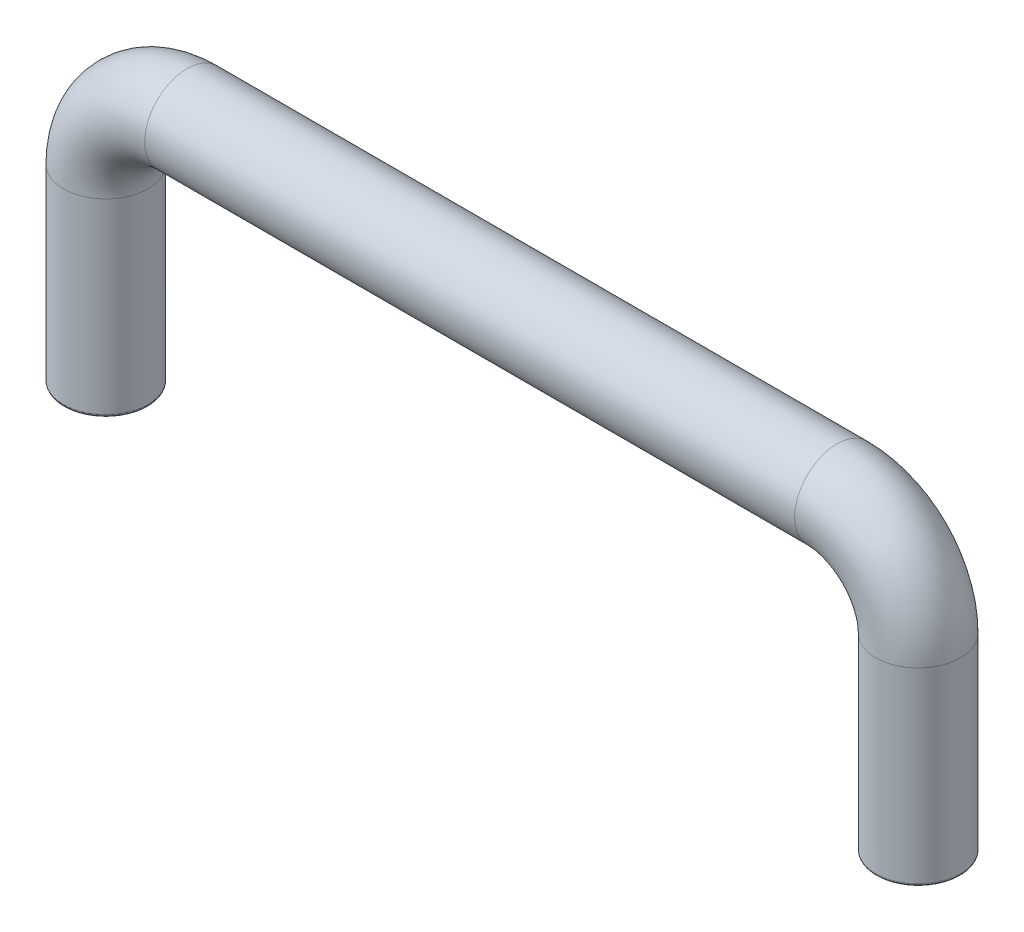
from build123d import *

# Parameters (mm, degrees)
SKETCH2_R                     = 3.96875
TAP_DRILL_FOR_8_32_TAP1_D     = 3.4544
TAP_DRILL_FOR_8_32_TAP1_DEPTH = 7.96925
TAP_DRILL_FOR_8_32_TAP1_TIP   = 1.037806461
FILLET1_R                     = 0.254


with BuildPart() as part:
    # Sweep5: sweep along a path in Sketch1
    with BuildLine(Plane.XY) as sweep5_path:
        Line((0, 0), (0, 17.78))
        ThreePointArc((0, 17.78), (2.231846327, 23.168153673), (7.62, 25.4))
        Line((7.62, 25.4), (68.58, 25.4))
        ThreePointArc((68.58, 25.4), (73.968153673, 23.168153673), (76.2, 17.78))
        Line((76.2, 17.78), (76.2, 0))
    # Sketch2 → Sweep5 (sweep)
    with BuildSketch(Plane(origin=(0, 0, 0), x_dir=(1, 0, 0), z_dir=(0, 1, 0))):
        with Locations((76.2, 0)):
            Circle(SKETCH2_R)
    sweep(path=sweep5_path.line)

    # Tap Drill for #8-32 Tap1
    with Locations(Plane(origin=(0, 0, 0), x_dir=(-1, 0, 0), z_dir=(0, -1, 0))):
        with Locations((-76.2, 0), (0, 0)):
            Hole(TAP_DRILL_FOR_8_32_TAP1_D / 2, depth=TAP_DRILL_FOR_8_32_TAP1_DEPTH)
            with Locations((0, 0, -(TAP_DRILL_FOR_8_32_TAP1_DEPTH + TAP_DRILL_FOR_8_32_TAP1_TIP / 2))):  # 118° drill point
                Cone(0, TAP_DRILL_FOR_8_32_TAP1_D / 2, TAP_DRILL_FOR_8_32_TAP1_TIP, mode=Mode.SUBTRACT)

    # Fillet1
    fillet1_edges = [part.edges().sort_by_distance(p)[0] for p in [
        (-1.7272, 0, 0),
        (74.4728, 0, 0),
        (72.23125, 0, 0),
        (3.96875, 0, 0),
    ]]
    fillet(fillet1_edges, radius=FILLET1_R)


solid = part.part
